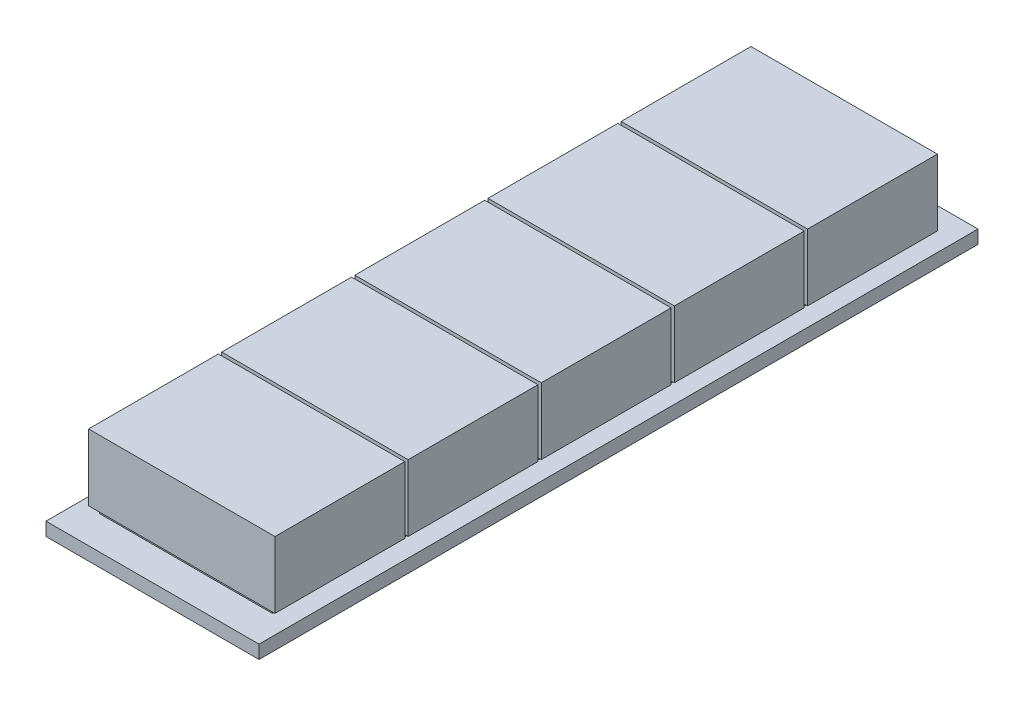
from build123d import *

# Parameters (mm, degrees)
SKETCH1_W           = 80
SKETCH1_H           = 270
BOSS_EXTRUDE1_DEPTH = 5
SKETCH2_W           = 65
SKETCH2_H           = 45
BOSS_EXTRUDE3_DEPTH = 2
LPATTERN1_COUNT     = 5
LPATTERN1_PITCH     = 50
SKETCH3_W           = 70
SKETCH3_H           = 48.748964222
BOSS_EXTRUDE8_DEPTH = 25
LPATTERN5_COUNT     = 5
LPATTERN5_PITCH     = 50


with BuildPart() as part:
    # Sketch1 → Boss-Extrude1 (new body)
    with BuildSketch(Plane(origin=(0, 0, 0), x_dir=(1, 0, 0), z_dir=(0, 1, 0))):
        Rectangle(SKETCH1_W, SKETCH1_H)
    extrude(amount=BOSS_EXTRUDE1_DEPTH)

    # Sketch2 → Boss-Extrude3 (add)
    with BuildSketch(Plane(origin=(0, 5, 0), x_dir=(1, 0, 0), z_dir=(0, 1, 0))):
        with Locations((0, -100)):
            Rectangle(SKETCH2_W, SKETCH2_H)
    boss_extrude3 = extrude(amount=BOSS_EXTRUDE3_DEPTH)

    # LPattern1: Boss-Extrude3 ×5
    with Locations(*[(0, 0, -i * LPATTERN1_PITCH) for i in range(1, LPATTERN1_COUNT)]):
        add(boss_extrude3)

    # Sketch3 → Boss-Extrude8 (add)
    with BuildSketch(Plane(origin=(0, 7, 0), x_dir=(1, 0, 0), z_dir=(0, 1, 0))):
        with Locations((0, -99.635002086)):
            Rectangle(SKETCH3_W, SKETCH3_H)
    boss_extrude8 = extrude(amount=BOSS_EXTRUDE8_DEPTH)

    # LPattern5: Boss-Extrude8 ×5
    with Locations(*[(0, 0, -i * LPATTERN5_PITCH) for i in range(1, LPATTERN5_COUNT)]):
        add(boss_extrude8)


solid = part.part
